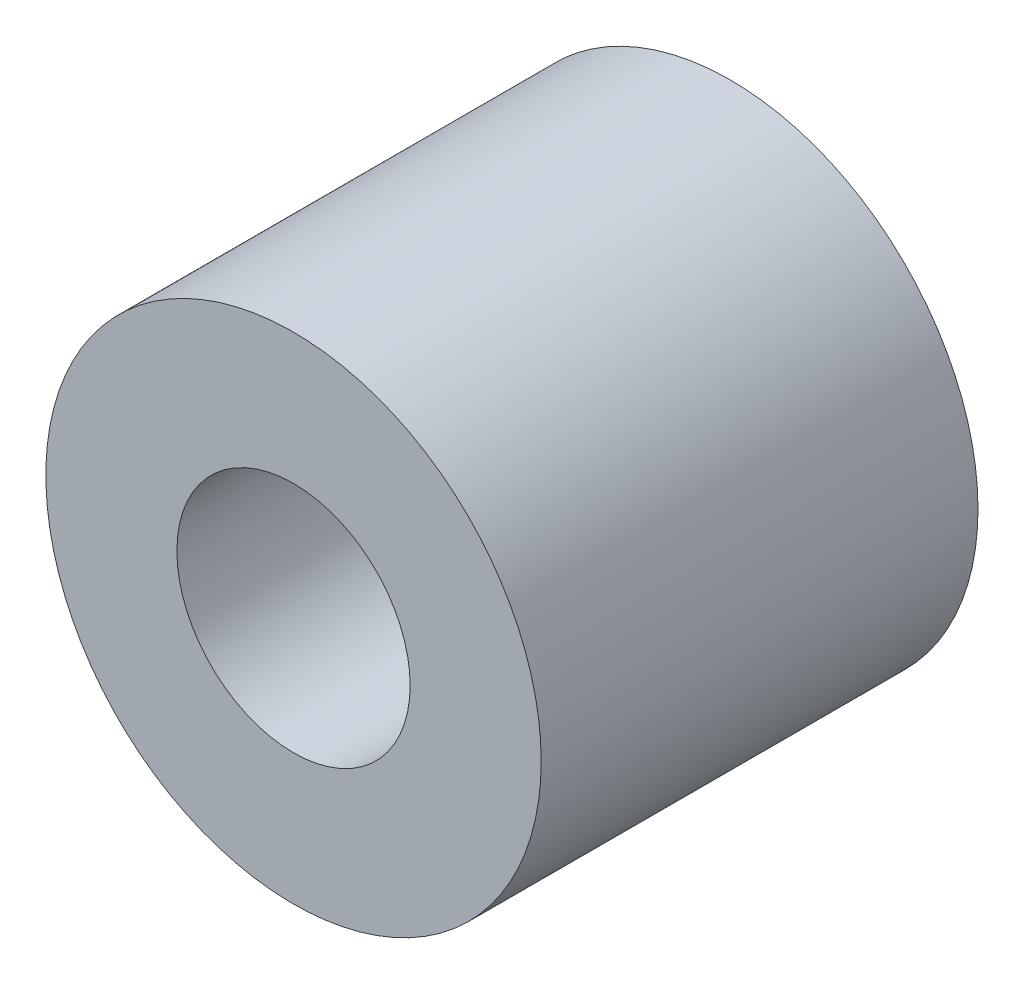
from build123d import *

# Parameters (mm, degrees)
SKETCH1_R           = 2.835
SKETCH1_R_2         = 1.335
BOSS_EXTRUDE1_DEPTH = 5


with BuildPart() as part:
    # Sketch1 → Boss-Extrude1 (new body)
    with BuildSketch(Plane.XY):
        Circle(SKETCH1_R)
        Circle(SKETCH1_R_2, mode=Mode.SUBTRACT)
    extrude(amount=BOSS_EXTRUDE1_DEPTH)


solid = part.part
